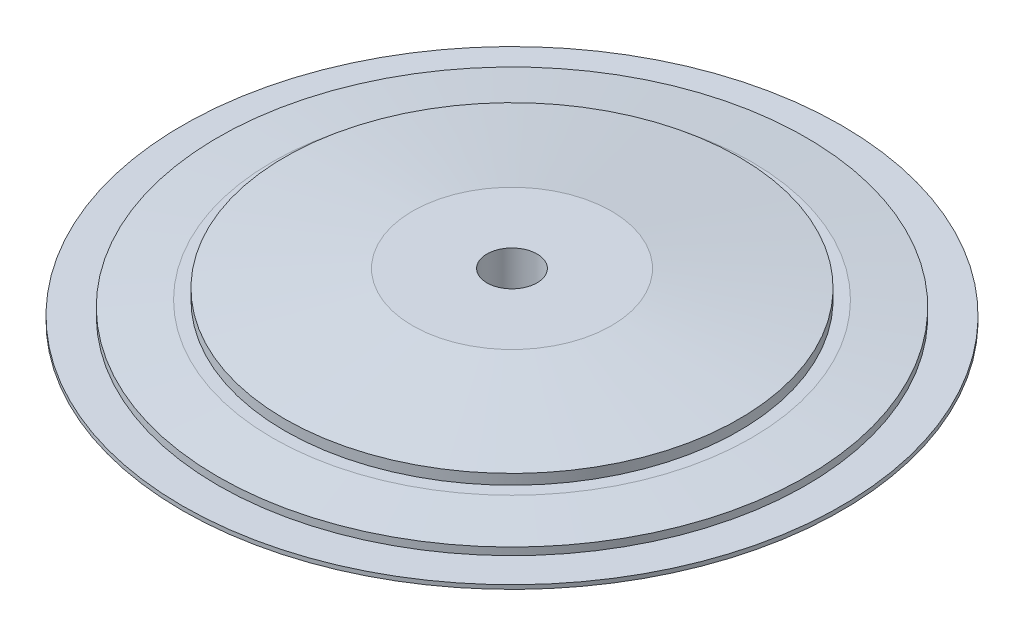
from build123d import *


with BuildPart() as part:
    # Sketch1 → Revolve1 (revolve)
    with BuildSketch(Plane.XY):
        Polygon((7.98816452, 0), (105.037977295, 0), (105.037977295, 1.300404607), (93.700113847, 1.300404607), (93.700113847, 3.678290341), (76.283697197, 5.654043612), (72.367869322, 5.654043612), (72.367869322, 8.91986549), (31.676164279, 14.337643353), (7.98816452, 14.337643353), align=None)
    revolve(axis=Axis((0, 11.676047175, 0), (0, -1, 0)))


solid = part.part
